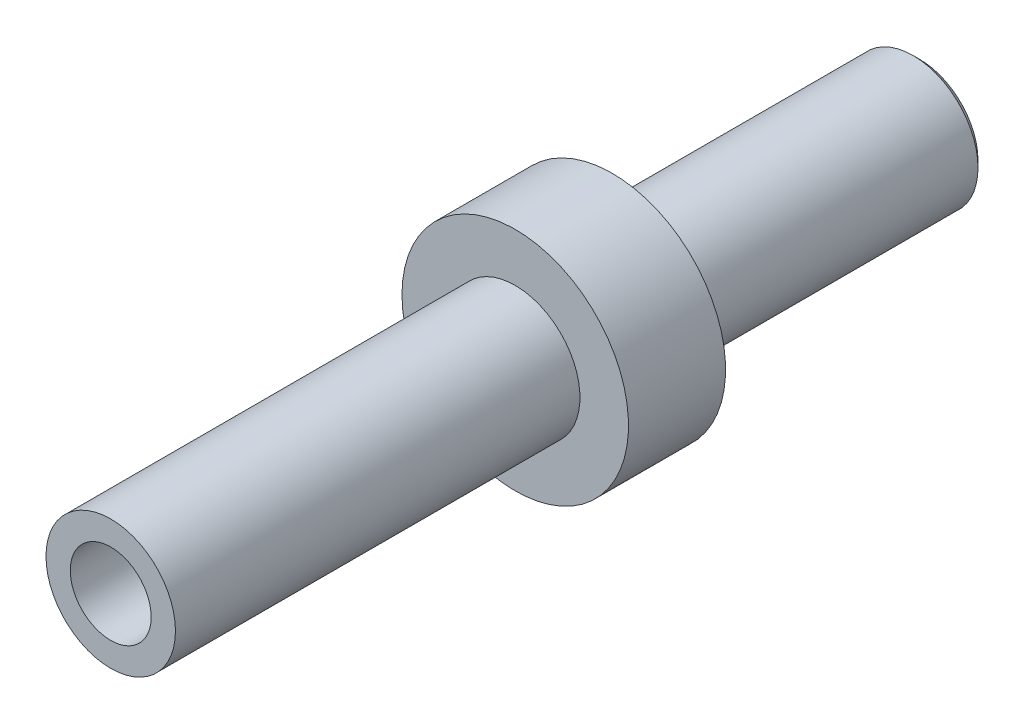
from build123d import *

# Parameters (mm, degrees)
SKETCH_1_R          = 2
EXTRUDE_1_DEPTH     = 25
SKETCH_2_R          = 1.25
CUT_EXTRUDE_1_DEPTH = 26
EXTRUDE_START       = -9.5
SKETCH_3_R          = 3.5
SKETCH_3_R_2        = 2
EXTRUDE_2_DEPTH     = 3
CHAMFER_1_SIZE      = 0.2


with BuildPart() as part:
    # Эскиз1 → Бобышка-Вытянуть1 (new body)
    with BuildSketch(Plane.XY):
        Circle(SKETCH_1_R)
    extrude(amount=EXTRUDE_1_DEPTH)

    # Эскиз2 → Вырез-Вытянуть1 (cut, through all)
    with BuildSketch(Plane.XY.offset(25)):
        Circle(SKETCH_2_R)
    extrude(amount=-CUT_EXTRUDE_1_DEPTH, mode=Mode.SUBTRACT)

    # Эскиз3 → Бобышка-Вытянуть2 (add)
    with BuildSketch(Plane(origin=(0, 0, 0), x_dir=(-1, 0, 0), z_dir=(0, 0, -1)).offset(EXTRUDE_START)):
        Circle(SKETCH_3_R)
        Circle(SKETCH_3_R_2, mode=Mode.SUBTRACT)
    extrude(amount=-EXTRUDE_2_DEPTH)

    # Фаска1
    chamfer_1_edges = [part.edges().sort_by_distance(p)[0] for p in [
        (-2, 0, 0),
    ]]
    chamfer(chamfer_1_edges, length=CHAMFER_1_SIZE)


solid = part.part
